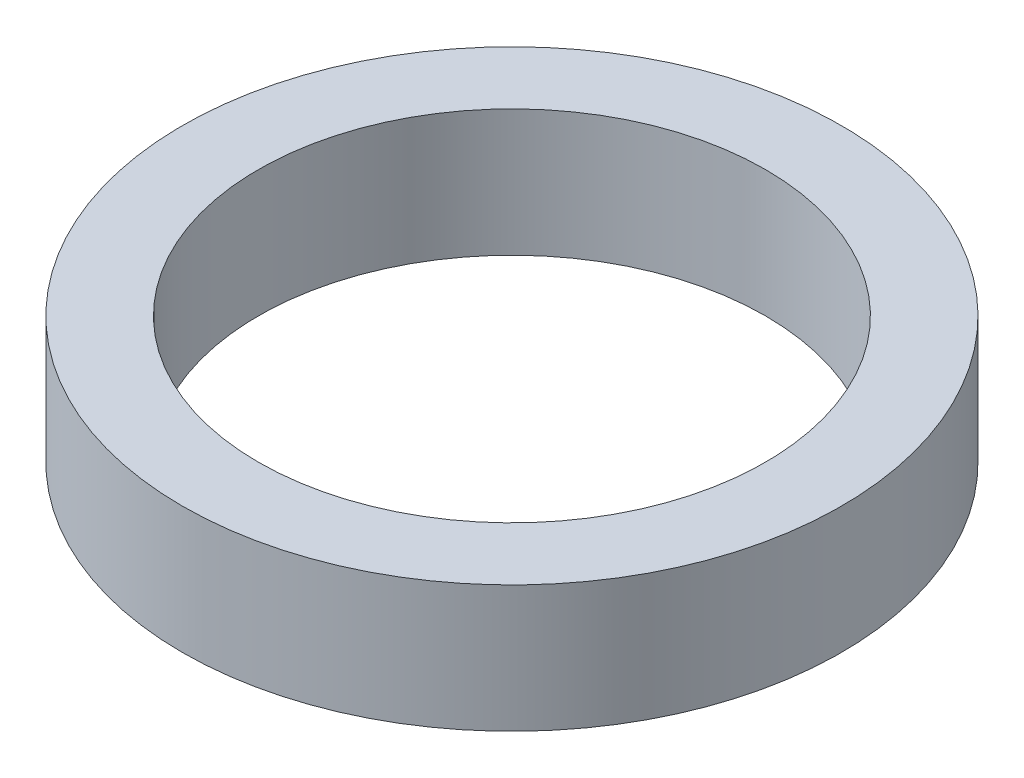
from build123d import *

# Parameters (mm, degrees)
SKETCH1_R           = 2.6
SKETCH1_R_2         = 2
BOSS_EXTRUDE1_DEPTH = 1


with BuildPart() as part:
    # Sketch1 → Boss-Extrude1 (new body)
    with BuildSketch(Plane(origin=(0, 0, 0), x_dir=(1, 0, 0), z_dir=(0, 1, 0))):
        Circle(SKETCH1_R)
        Circle(SKETCH1_R_2, mode=Mode.SUBTRACT)
    extrude(amount=BOSS_EXTRUDE1_DEPTH)


solid = part.part
